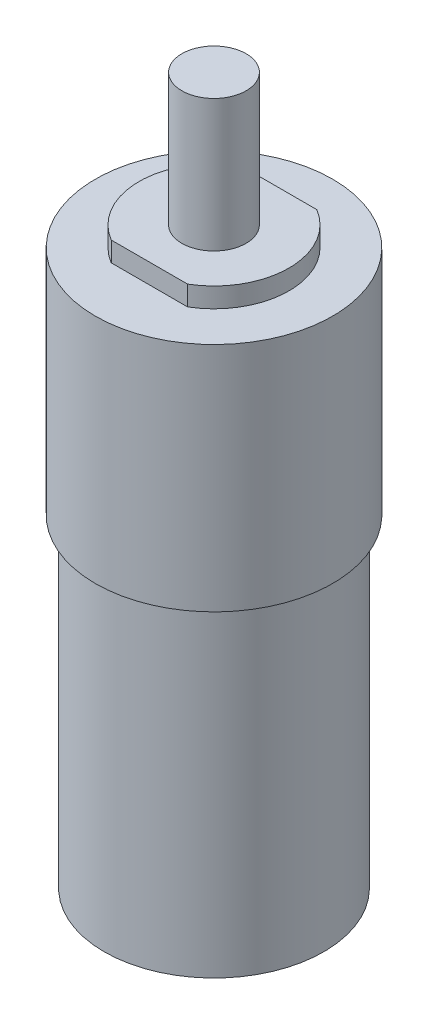
from build123d import *

# Parameters (mm, degrees)
SKETCH1_R           = 10.16
BOSS_EXTRUDE1_DEPTH = 29.8958
SKETCH2_R           = 10.9728
BOSS_EXTRUDE2_DEPTH = 21.4122
SKETCH3_R           = 6.9342
BOSS_EXTRUDE3_DEPTH = 1.8288
BOSS_EXTRUDE4_START = -53.1368
SKETCH4_R           = 2.9718
BOSS_EXTRUDE4_DEPTH = 65.3542
CUT_EXTRUDE1_DEPTH  = 1.8288


with BuildPart() as part:
    # Sketch1 → Boss-Extrude1 (new body)
    with BuildSketch(Plane(origin=(0, 0, 0), x_dir=(1, 0, 0), z_dir=(0, 1, 0))):
        Circle(SKETCH1_R)
    extrude(amount=BOSS_EXTRUDE1_DEPTH)

    # Sketch2 → Boss-Extrude2 (add)
    with BuildSketch(Plane(origin=(0, 29.8958, 0), x_dir=(1, 0, 0), z_dir=(0, 1, 0))):
        Circle(SKETCH2_R)
    extrude(amount=BOSS_EXTRUDE2_DEPTH)

    # Sketch3 → Boss-Extrude3 (add)
    with BuildSketch(Plane(origin=(0, 51.308, 0), x_dir=(1, 0, 0), z_dir=(0, 1, 0))):
        Circle(SKETCH3_R)
    extrude(amount=BOSS_EXTRUDE3_DEPTH)

    # Sketch4 → Boss-Extrude4 (add)
    with BuildSketch(Plane(origin=(0, 53.1368, 0), x_dir=(1, 0, 0), z_dir=(0, 1, 0)).offset(BOSS_EXTRUDE4_START)):
        Circle(SKETCH4_R)
    extrude(amount=BOSS_EXTRUDE4_DEPTH)

    # Sketch5 → Cut-Extrude1 (cut)
    with BuildSketch(Plane(origin=(0, 53.1368, 0), x_dir=(1, 0, 0), z_dir=(0, 1, 0))):
        with BuildLine():
            Line((-3.529046421, 5.969), (3.529046421, 5.969))
            ThreePointArc((3.529046421, 5.969), (0, 6.9342), (-3.529046421, 5.969))
        make_face()
        with BuildLine():
            Line((3.529046421, -5.969), (-3.529046421, -5.969))
            ThreePointArc((-3.529046421, -5.969), (0, -6.9342), (3.529046421, -5.969))
        make_face()
    extrude(amount=-CUT_EXTRUDE1_DEPTH, mode=Mode.SUBTRACT)


solid = part.part
